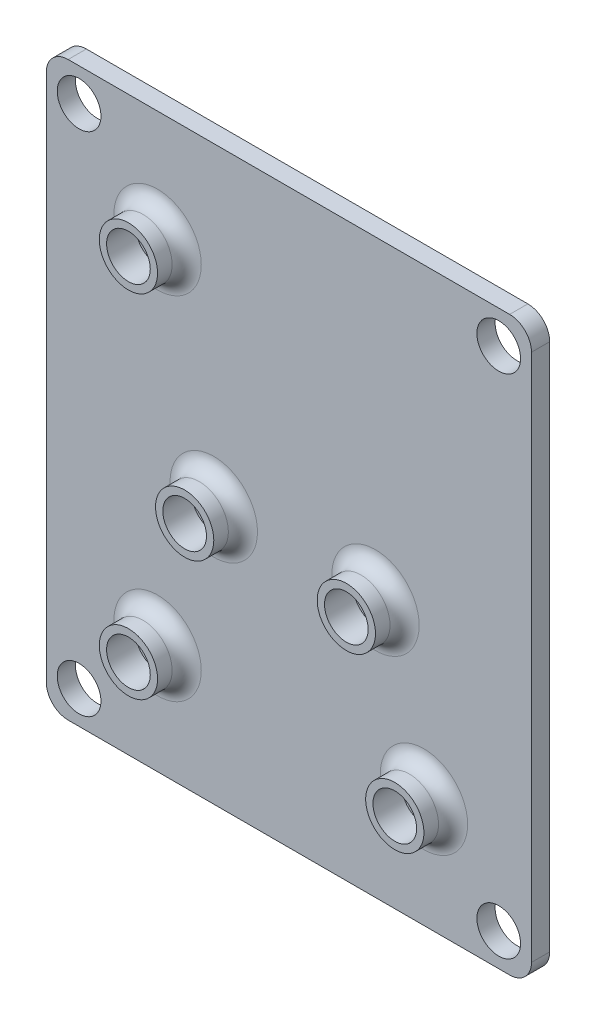
from build123d import *

# Parameters (mm, degrees)
SKETCH1_W           = 33.311980516
SKETCH1_H           = 39.280980516
SKETCH1_R           = 1.5
BOSS_EXTRUDE1_DEPTH = 1.25
FILLET1_R           = 1.5
SKETCH1_16_R        = 2
SKETCH1_16_R_2      = 1.5
BOSS_EXTRUDE2_DEPTH = 2
FILLET2_R           = 1


with BuildPart() as part:
    # Sketch1 → Boss-Extrude1 (new body)
    with BuildSketch(Plane.XY):
        with Locations((12.065, 15.0495)):
            Rectangle(SKETCH1_W, SKETCH1_H)
        with Locations((-2.340990258, -2.340990258)):
            Circle(SKETCH1_R, mode=Mode.SUBTRACT)
        with Locations((26.470990258, -2.340990258)):
            Circle(SKETCH1_R, mode=Mode.SUBTRACT)
        with Locations((-2.340990258, 32.439990258)):
            Circle(SKETCH1_R, mode=Mode.SUBTRACT)
        with Locations((26.470990258, 32.439990258)):
            Circle(SKETCH1_R, mode=Mode.SUBTRACT)
    extrude(amount=-BOSS_EXTRUDE1_DEPTH)

    # Fillet1
    fillet1_edges = [part.edges().sort_by_distance(p)[0] for p in [
        (-4.590990258, -4.590990258, -0.625),
        (-4.590990258, 34.689990258, -0.625),
        (28.720990258, 34.689990258, -0.625),
        (28.720990258, -4.590990258, -0.625),
    ]]
    fillet(fillet1_edges, radius=FILLET1_R)

    # Sketch1_16 → Boss-Extrude2 (add)
    # profile 1 of 5: a face of its own
    with BuildSketch(Plane.XY):
        with Locations((3.048, 2.921)):
            Circle(SKETCH1_16_R)
        with Locations((3.048, 2.921)):
            Circle(SKETCH1_16_R_2, mode=Mode.SUBTRACT)
    # profile 2 of 5: a face of its own
    with BuildSketch(Plane.XY):
        with Locations((6.908038, 13.09497)):
            Circle(SKETCH1_16_R)
        with Locations((6.908038, 13.09497)):
            Circle(SKETCH1_16_R_2, mode=Mode.SUBTRACT)
    # profile 3 of 5: a face of its own
    with BuildSketch(Plane.XY):
        with Locations((18.008092, 13.09497)):
            Circle(SKETCH1_16_R)
        with Locations((18.008092, 13.09497)):
            Circle(SKETCH1_16_R_2, mode=Mode.SUBTRACT)
    # profile 4 of 5: a face of its own
    with BuildSketch(Plane.XY):
        with Locations((21.336, 2.921)):
            Circle(SKETCH1_16_R)
        with Locations((21.336, 2.921)):
            Circle(SKETCH1_16_R_2, mode=Mode.SUBTRACT)
    # profile 5 of 5: a face of its own
    with BuildSketch(Plane.XY):
        with Locations((3.048, 27.051)):
            Circle(SKETCH1_16_R)
        with Locations((3.048, 27.051)):
            Circle(SKETCH1_16_R_2, mode=Mode.SUBTRACT)
    extrude(amount=BOSS_EXTRUDE2_DEPTH)

    # Fillet2
    fillet2_edges = [part.edges().sort_by_distance(p)[0] for p in [
        (1.048, 2.921, 0),
        (19.336, 2.921, 0),
        (16.008092, 13.09497, 0),
        (4.908038, 13.09497, 0),
        (1.048, 27.051, 0),
    ]]
    fillet(fillet2_edges, radius=FILLET2_R)


solid = part.part
